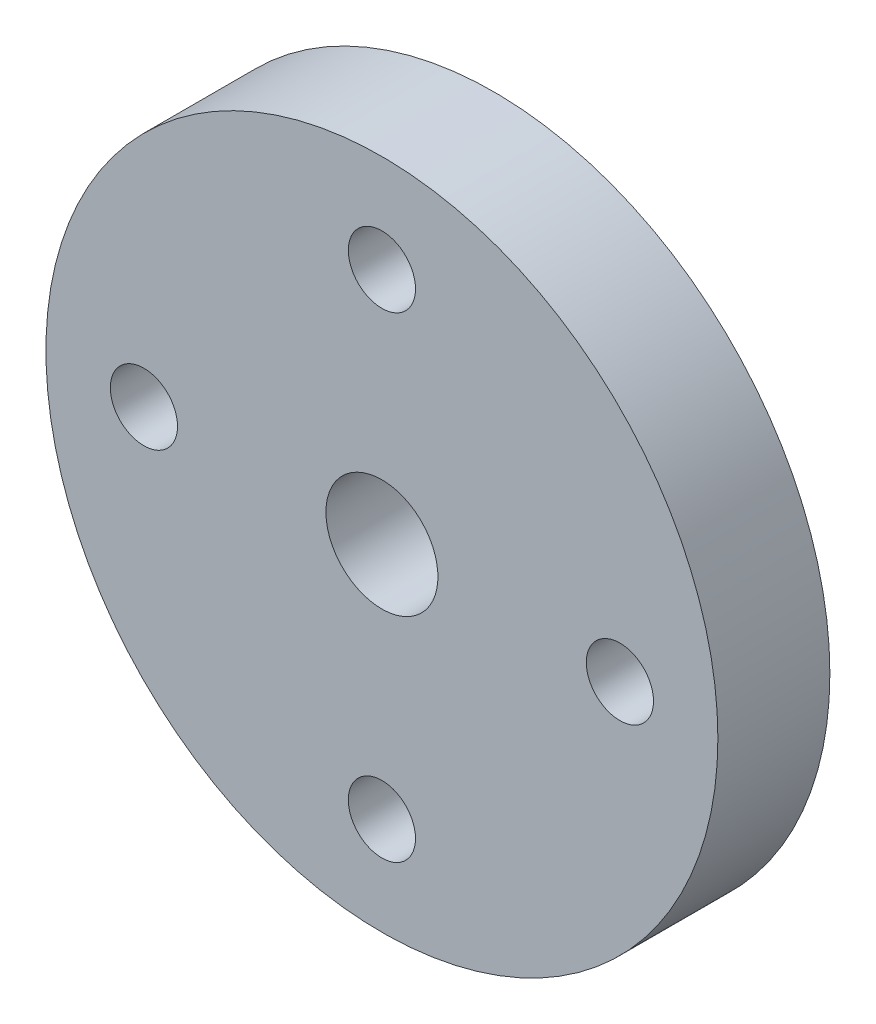
from build123d import *

# Parameters (mm, degrees)
SKETCH1_R           = 30
SKETCH1_R_2         = 3
BOSS_EXTRUDE3_DEPTH = 10
SKETCH2_R           = 10
BOSS_EXTRUDE4_DEPTH = 10
SKETCH3_R           = 5
CUT_EXTRUDE1_DEPTH  = 21


with BuildPart() as part:
    # Sketch1 → Boss-Extrude3 (new body)
    with BuildSketch(Plane.XY):
        Circle(SKETCH1_R)
        with Locations((0, 21.25)):
            Circle(SKETCH1_R_2, mode=Mode.SUBTRACT)
        with Locations((21.25, 0)):
            Circle(SKETCH1_R_2, mode=Mode.SUBTRACT)
        with Locations((0, -21.25)):
            Circle(SKETCH1_R_2, mode=Mode.SUBTRACT)
        with Locations((-21.25, 0)):
            Circle(SKETCH1_R_2, mode=Mode.SUBTRACT)
    extrude(amount=BOSS_EXTRUDE3_DEPTH)

    # Sketch2 → Boss-Extrude4 (add)
    with BuildSketch(Plane(origin=(0, 0, 0), x_dir=(-1, 0, 0), z_dir=(0, 0, -1))):
        Circle(SKETCH2_R)
    extrude(amount=BOSS_EXTRUDE4_DEPTH)

    # Sketch3 → Cut-Extrude1 (cut, through all)
    with BuildSketch(Plane(origin=(0, 0, -10), x_dir=(-1, 0, 0), z_dir=(0, 0, -1))):
        Circle(SKETCH3_R)
    extrude(amount=-CUT_EXTRUDE1_DEPTH, mode=Mode.SUBTRACT)


solid = part.part
